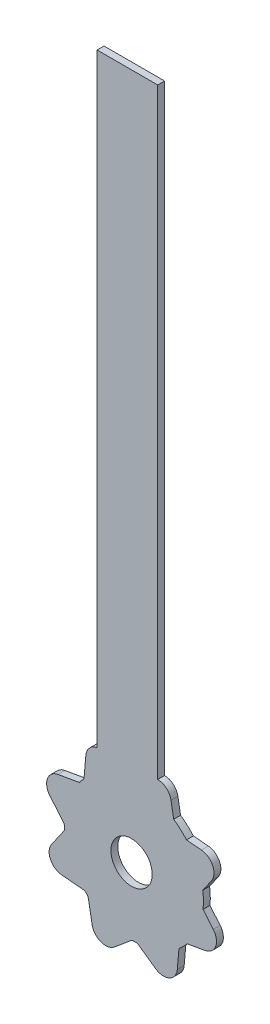
from build123d import *

# Parameters (mm, degrees)
IZIM1_R                     = 5
Y_KSEKLIK_EKSTR_ZYON2_DEPTH = 1
IZIM2_R                     = 3
Y_KSEKLIK_EKSTR_ZYON4_DEPTH = 1


with BuildPart() as part:
    # Çizim1 → Yükseklik-Ekstrüzyon2 (new body)
    with BuildSketch(Plane.XY):
        with BuildLine():
            Line((-16.200531831, -56.860261047), (-16.200531831, 33.139738953))
            Line((-16.200531831, 33.139738953), (-25, 33.139738953))
            Line((-25, 33.139738953), (-25, -57.883306535))
            ThreePointArc((-25, -57.883306535), (-18.410044855, -76.210418758), (-16.200531831, -56.860261047))
        make_face()
        with Locations((-19.564888058, -66.277325727)):
            Circle(IZIM1_R, mode=Mode.SUBTRACT)
    extrude(amount=Y_KSEKLIK_EKSTR_ZYON2_DEPTH)

    # Çizim2 → Yükseklik-Ekstrüzyon4 (add)
    with BuildSketch(Plane.XY.offset(1)):
        with BuildLine():
            Line((-14.268162917, -55.859645389), (-13.746523784, -58.818007922))
            ThreePointArc((-13.746523784, -58.818007922), (-13.437306239, -59.381637082), (-12.848871774, -59.640554443))
            Line((-12.848871774, -59.640554443), (-9.856302857, -59.902370298))
            ThreePointArc((-9.856302857, -59.902370298), (-8.217998769, -61.049523171), (-8.392310254, -63.041912567))
            Line((-8.392310254, -63.041912567), (-10.115333894, -65.502645344))
            ThreePointArc((-10.115333894, -65.502645344), (-10.295230071, -66.119841167), (-10.062226293, -66.71900939))
            Line((-10.062226293, -66.71900939), (-8.131292285, -69.02020693))
            ThreePointArc((-8.131292285, -69.02020693), (-7.78399593, -70.989822436), (-9.316084816, -72.275397656))
            Line((-9.316084816, -72.275397656), (-12.274447349, -72.797036789))
            ThreePointArc((-12.274447349, -72.797036789), (-12.838076508, -73.106254334), (-13.09699387, -73.694688799))
            Line((-13.09699387, -73.694688799), (-13.358809725, -76.687257716))
            ThreePointArc((-13.358809725, -76.687257716), (-14.505962597, -78.325561805), (-16.498351994, -78.151250319))
            Line((-16.498351994, -78.151250319), (-18.95908477, -76.428226679))
            ThreePointArc((-18.95908477, -76.428226679), (-19.576280594, -76.248330502), (-20.175448817, -76.48133428))
            Line((-20.175448817, -76.48133428), (-22.476646357, -78.412268288))
            ThreePointArc((-22.476646357, -78.412268288), (-24.446261863, -78.759564643), (-25.731837083, -77.227475757))
            Line((-25.731837083, -77.227475757), (-26.253476216, -74.269113224))
            ThreePointArc((-26.253476216, -74.269113224), (-26.562693761, -73.705484065), (-27.151128226, -73.446566704))
            Line((-27.151128226, -73.446566704), (-30.143697143, -73.184750849))
            ThreePointArc((-30.143697143, -73.184750849), (-31.782001231, -72.037597976), (-31.607689746, -70.04520858))
            Line((-31.607689746, -70.04520858), (-29.884666106, -67.584475803))
            ThreePointArc((-29.884666106, -67.584475803), (-29.704769929, -66.967279979), (-29.937773707, -66.368111757))
            Line((-29.937773707, -66.368111757), (-31.868707715, -64.066914216))
            ThreePointArc((-31.868707715, -64.066914216), (-32.21600407, -62.09729871), (-30.683915184, -60.811723491))
            Line((-30.683915184, -60.811723491), (-27.725552651, -60.290084357))
            ThreePointArc((-27.725552651, -60.290084357), (-27.161923492, -59.980866812), (-26.90300613, -59.392432347))
            Line((-26.90300613, -59.392432347), (-26.641190275, -56.39986343))
            ThreePointArc((-26.641190275, -56.39986343), (-25.494037403, -54.761559342), (-23.501648006, -54.935870827))
            Line((-23.501648006, -54.935870827), (-21.04091523, -56.658894467))
            ThreePointArc((-21.04091523, -56.658894467), (-20.423719406, -56.838790644), (-19.824551183, -56.605786866))
            Line((-19.824551183, -56.605786866), (-17.523353643, -54.674852858))
            ThreePointArc((-17.523353643, -54.674852858), (-15.553738137, -54.327556503), (-14.268162917, -55.859645389))
        make_face()
        with Locations((-20, -66.543560573)):
            Circle(IZIM2_R, mode=Mode.SUBTRACT)
    extrude(amount=-Y_KSEKLIK_EKSTR_ZYON4_DEPTH)


solid = part.part
